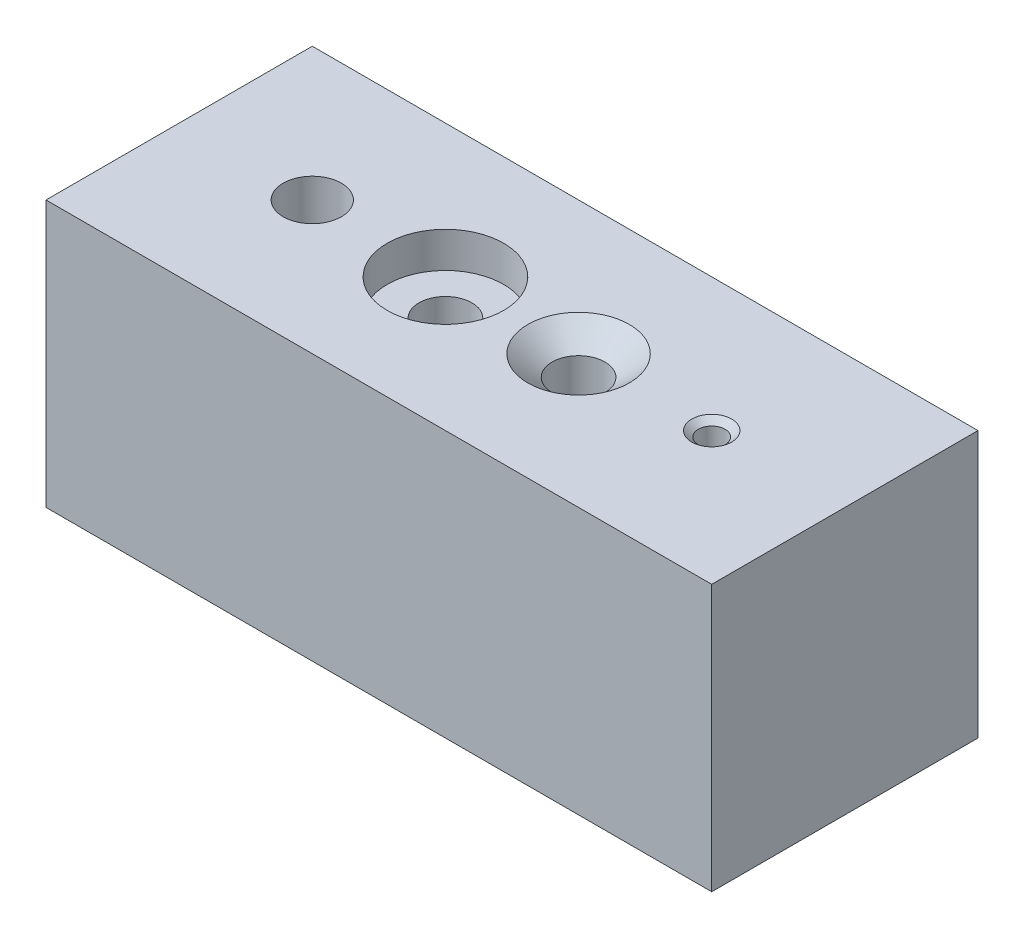
from build123d import *

# Parameters (mm, degrees)
SKETCH1_W                                           = 127
SKETCH1_H                                           = 50.8
BOSS_EXTRUDE1_DEPTH                                 = 50.8
F_7_16_0_4375_DIAMETER_HOLE2_D                      = 11.1125
F_7_16_0_4375_DIAMETER_HOLE2_DEPTH                  = 19.05
F_7_16_0_4375_DIAMETER_HOLE2_TIP                    = 3.338531814
CBORE_FOR_3_8_HEX_HEAD_BOLT1_D                      = 10.0838
CBORE_FOR_3_8_HEX_HEAD_BOLT1_CBORE_D                = 22.225
CBORE_FOR_3_8_HEX_HEAD_BOLT1_CBORE_DEPTH            = 6.8072
CSK_FOR_3_8_FLAT_HEAD_MACHINE_SCREW_100_D           = 10.0838
CSK_FOR_3_8_FLAT_HEAD_MACHINE_SCREW_100_DEPTH       = 38.1
CSK_FOR_3_8_FLAT_HEAD_MACHINE_SCREW_100_CSINK_D     = 19.3548
CSK_FOR_3_8_FLAT_HEAD_MACHINE_SCREW_100_CSINK_ANGLE = 100
CSK_FOR_3_8_FLAT_HEAD_MACHINE_SCREW_100_TIP         = 3.029479155
F_1_4_20_TAPPED_HOLE1_D                             = 5.1054
F_1_4_20_TAPPED_HOLE1_DEPTH                         = 25.4
F_1_4_20_TAPPED_HOLE1_CSINK_D                       = 7.62
F_1_4_20_TAPPED_HOLE1_CSINK_ANGLE                   = 100
F_1_4_20_TAPPED_HOLE1_TIP                           = 1.533816902


with BuildPart() as part:
    # Sketch1 → Boss-Extrude1 (new body)
    with BuildSketch(Plane.XY):
        Rectangle(SKETCH1_W, SKETCH1_H)
    extrude(amount=BOSS_EXTRUDE1_DEPTH)

    # 7/16 (0.4375) Diameter Hole2
    with Locations(Plane(origin=(-38.1, 25.4, 25.4), x_dir=(0, 0, 1), z_dir=(0, 1, 0))):
        with Locations((0, 0)):
            Hole(F_7_16_0_4375_DIAMETER_HOLE2_D / 2, depth=F_7_16_0_4375_DIAMETER_HOLE2_DEPTH)
            with Locations((0, 0, -(F_7_16_0_4375_DIAMETER_HOLE2_DEPTH + F_7_16_0_4375_DIAMETER_HOLE2_TIP / 2))):  # 118° drill point
                Cone(0, F_7_16_0_4375_DIAMETER_HOLE2_D / 2, F_7_16_0_4375_DIAMETER_HOLE2_TIP, mode=Mode.SUBTRACT)

    # CBORE for 3/8 Hex Head Bolt1 (through all)
    with Locations(Plane(origin=(-12.7, 25.4, 25.4), x_dir=(0, 0, 1), z_dir=(0, 1, 0))):
        with Locations((0, 0)):
            CounterBoreHole(CBORE_FOR_3_8_HEX_HEAD_BOLT1_D / 2, CBORE_FOR_3_8_HEX_HEAD_BOLT1_CBORE_D / 2, CBORE_FOR_3_8_HEX_HEAD_BOLT1_CBORE_DEPTH)

    # CSK for 3/8 Flat Head Machine Screw (100)1
    with Locations(Plane(origin=(12.7, 25.4, 25.4), x_dir=(0, 0, 1), z_dir=(0, 1, 0))):
        with Locations((0, 0)):
            CounterSinkHole(CSK_FOR_3_8_FLAT_HEAD_MACHINE_SCREW_100_D / 2, CSK_FOR_3_8_FLAT_HEAD_MACHINE_SCREW_100_CSINK_D / 2, depth=CSK_FOR_3_8_FLAT_HEAD_MACHINE_SCREW_100_DEPTH, counter_sink_angle=CSK_FOR_3_8_FLAT_HEAD_MACHINE_SCREW_100_CSINK_ANGLE)
            with Locations((0, 0, -(CSK_FOR_3_8_FLAT_HEAD_MACHINE_SCREW_100_DEPTH + CSK_FOR_3_8_FLAT_HEAD_MACHINE_SCREW_100_TIP / 2))):  # 118° drill point
                Cone(0, CSK_FOR_3_8_FLAT_HEAD_MACHINE_SCREW_100_D / 2, CSK_FOR_3_8_FLAT_HEAD_MACHINE_SCREW_100_TIP, mode=Mode.SUBTRACT)

    # 1/4-20 Tapped Hole1
    with Locations(Plane(origin=(38.1, 25.4, 25.4), x_dir=(0, 0, 1), z_dir=(0, 1, 0))):
        with Locations((0, 0)):
            CounterSinkHole(F_1_4_20_TAPPED_HOLE1_D / 2, F_1_4_20_TAPPED_HOLE1_CSINK_D / 2, depth=F_1_4_20_TAPPED_HOLE1_DEPTH, counter_sink_angle=F_1_4_20_TAPPED_HOLE1_CSINK_ANGLE)
            with Locations((0, 0, -(F_1_4_20_TAPPED_HOLE1_DEPTH + F_1_4_20_TAPPED_HOLE1_TIP / 2))):  # 118° drill point
                Cone(0, F_1_4_20_TAPPED_HOLE1_D / 2, F_1_4_20_TAPPED_HOLE1_TIP, mode=Mode.SUBTRACT)


solid = part.part
